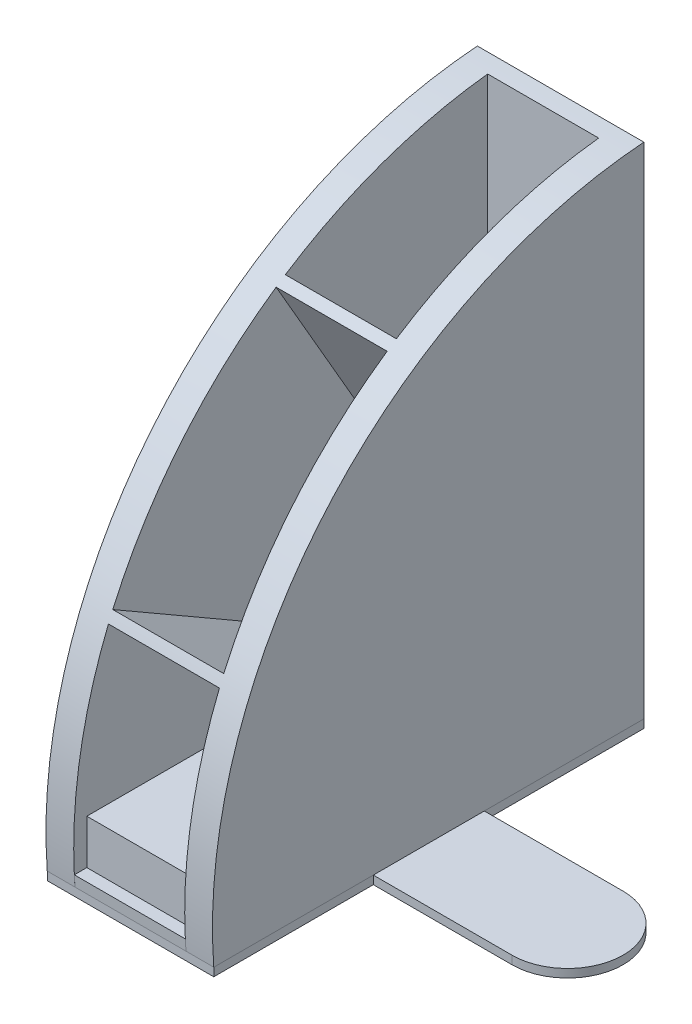
from build123d import *

# Parameters (mm, degrees)
BOSS_EXTRUDE1_DEPTH  = 10
SKETCH2_W            = 150.741836367
SKETCH2_H            = 20
BOSS_EXTRUDE2_DEPTH  = 40
BOSS_EXTRUDE3_START  = 50
BOSS_EXTRUDE3_DEPTH  = 10
BOSS_EXTRUDE4_REACH  = 52
BOSS_EXTRUDE5_REACH  = 52
BOSS_EXTRUDE8_DEPTH  = 40
BOSS_EXTRUDE9_DEPTH  = 40
BOSS_EXTRUDE10_DEPTH = 3


with BuildPart() as part:
    # Sketch1 → Boss-Extrude1 (new body)
    with BuildSketch(Plane(origin=(0, 0, 0), x_dir=(0, 0, -1), z_dir=(1, 0, 0))):
        with BuildLine():
            Line((0, 0), (-155, 0))
            ThreePointArc((-155, 0), (-114.779220614, 122.101551084), (0, 180))
            Line((0, 180), (0, 0))
        make_face()
    extrude(amount=BOSS_EXTRUDE1_DEPTH)

    # Sketch2 → Boss-Extrude2 (add)
    with BuildSketch(Plane(origin=(10, 0, 0), x_dir=(0, 0, -1), z_dir=(1, 0, 0))):
        with Locations((-75.370918184, 10)):
            Rectangle(SKETCH2_W, SKETCH2_H)
    extrude(amount=BOSS_EXTRUDE2_DEPTH)

    # Sketch1_2 → Boss-Extrude3 (add)
    with BuildSketch(Plane(origin=(0, 0, 0), x_dir=(0, 0, -1), z_dir=(1, 0, 0)).offset(BOSS_EXTRUDE3_START)):
        with BuildLine():
            Line((0, 0), (-155, 0))
            ThreePointArc((-155, 0), (-114.779220614, 122.101551084), (0, 180))
            Line((0, 180), (0, 0))
        make_face()
    extrude(amount=BOSS_EXTRUDE3_DEPTH)

    # Sketch3 → Boss-Extrude4 (add, up to next)
    with BuildSketch(Plane(origin=(10, 0, 0), x_dir=(0, 0, -1), z_dir=(1, 0, 0)), mode=Mode.PRIVATE) as boss_extrude4_sk1:
        Polygon((-155, 0), (-155.248344232, 3.956405475), (-150.741836367, 3.956405475), (-150.741836367, 0), align=None)
    boss_extrude4_tool1 = extrude(boss_extrude4_sk1.sketch, amount=BOSS_EXTRUDE4_REACH, mode=Mode.PRIVATE) - part.part
    add(boss_extrude4_tool1.solids().sort_by_distance((10, 1.996887, 152.933591))[0])

    # Sketch4 → Boss-Extrude5 (add, up to next)
    with BuildSketch(Plane.ZY.offset(-50), mode=Mode.PRIVATE) as boss_extrude5_sk1:
        with BuildLine():
            Line((6.285027821, 179.412020927), (6.285027821, 20))
            Line((6.285027821, 20), (0, 20))
            Line((0, 20), (0, 180))
            ThreePointArc((0, 180), (3.145276325, 179.735538474), (6.285027821, 179.412020927))
        make_face()
    boss_extrude5_tool1 = extrude(boss_extrude5_sk1.sketch, amount=BOSS_EXTRUDE5_REACH, mode=Mode.PRIVATE) - part.part
    add(boss_extrude5_tool1.solids().sort_by_distance((50, 99.863025, 3.140586))[0])

    # Sketch5 → Boss-Extrude8 (add)
    with BuildSketch(Plane(origin=(10, 0, 0), x_dir=(0, 0, -1), z_dir=(1, 0, 0))):
        with BuildLine():
            ThreePointArc((-15.995737166, 35.766562367), (-14.26647513, 36.773818207), (-12.486075374, 37.687649826))
            Line((-12.486075374, 37.687649826), (-79.194018797, 153.229197102))
            ThreePointArc((-79.194018797, 153.229197102), (-80.866814116, 152.124990678), (-82.526313815, 151.000901379))
            Line((-82.526313815, 151.000901379), (-15.995737166, 35.766562367))
        make_face()
        with BuildLine():
            Line((-142.957405316, 76.104206878), (-32.791687428, 12.5))
            ThreePointArc((-32.791687428, 12.5), (-32.260504097, 14.48758469), (-31.621412378, 16.443143538))
            Line((-31.621412378, 16.443143538), (-141.38648706, 79.816038953))
            ThreePointArc((-141.38648706, 79.816038953), (-142.183080399, 77.964835127), (-142.957405316, 76.104206878))
        make_face()
    extrude(amount=BOSS_EXTRUDE8_DEPTH)

    # Sketch5_4 → Boss-Extrude9 (add)
    with BuildSketch(Plane(origin=(10, 0, 0), x_dir=(0, 0, -1), z_dir=(1, 0, 0))):
        with BuildLine():
            Line((-6.285027821, 20), (-6.285027821, 40.017504829))
            ThreePointArc((-6.285027821, 40.017504829), (-9.436955605, 38.989392149), (-12.486075374, 37.687649826))
            ThreePointArc((-12.486075374, 37.687649826), (-14.26647513, 36.773818207), (-15.995737166, 35.766562367))
            ThreePointArc((-15.995737166, 35.766562367), (-24.201304285, 28.899827943), (-30.140701221, 20))
            Line((-30.140701221, 20), (-6.285027821, 20))
        make_face()
    extrude(amount=BOSS_EXTRUDE9_DEPTH)


with BuildPart() as body_2:
    # Sketch6 → Boss-Extrude10 (new body)
    with BuildSketch(Plane.XZ):
        with BuildLine():
            Line((110, 97.5), (60, 97.5))
            Line((60, 97.5), (60, 57.5))
            Line((60, 57.5), (110, 57.5))
            ThreePointArc((110, 57.5), (130, 77.5), (110, 97.5))
        make_face()
        Polygon((10, 155), (0, 155), (0, 0), (60, 0), (60, 155), (50, 155), align=None)
    extrude(amount=BOSS_EXTRUDE10_DEPTH)


solid = Compound([part.part, body_2.part])
